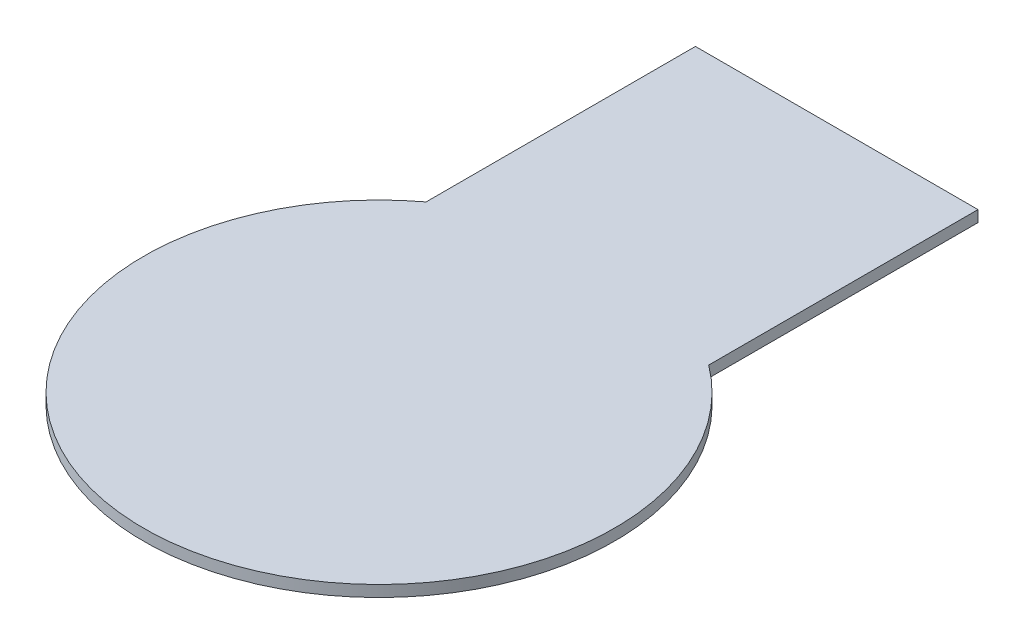
from build123d import *

# Parameters (mm, degrees)
BOSS_EXTRUDE1_DEPTH = 0.6


with BuildPart() as part:
    # Sketch1 → Boss-Extrude1 (new body)
    with BuildSketch(Plane(origin=(0, 0, 0), x_dir=(1, 0, 0), z_dir=(0, 1, 0))):
        with BuildLine():
            ThreePointArc((7.5, 10), (0, 12.5), (-7.5, 10))
            Line((-7.5, 10), (-7.5, 0.704545455))
            Line((-7.5, 0.704545455), (7.5, 0.704545455))
            Line((7.5, 0.704545455), (7.5, 10))
        make_face()
        with BuildLine():
            Line((-7.5, 0.704545455), (-7.5, 10))
            ThreePointArc((-7.5, 10), (-5.590169944, -11.180339887), (12.5, 0))
            ThreePointArc((12.5, 0), (11.180339887, 5.590169944), (7.5, 10))
            Line((7.5, 10), (7.5, 0.704545455))
            Line((7.5, 0.704545455), (-7.5, 0.704545455))
        make_face()
        with BuildLine():
            Line((7.5, 24.295454545), (-7.5, 24.295454545))
            Line((-7.5, 24.295454545), (-7.5, 10))
            ThreePointArc((-7.5, 10), (0, 12.5), (7.5, 10))
            Line((7.5, 10), (7.5, 24.295454545))
        make_face()
    extrude(amount=BOSS_EXTRUDE1_DEPTH)


solid = part.part
